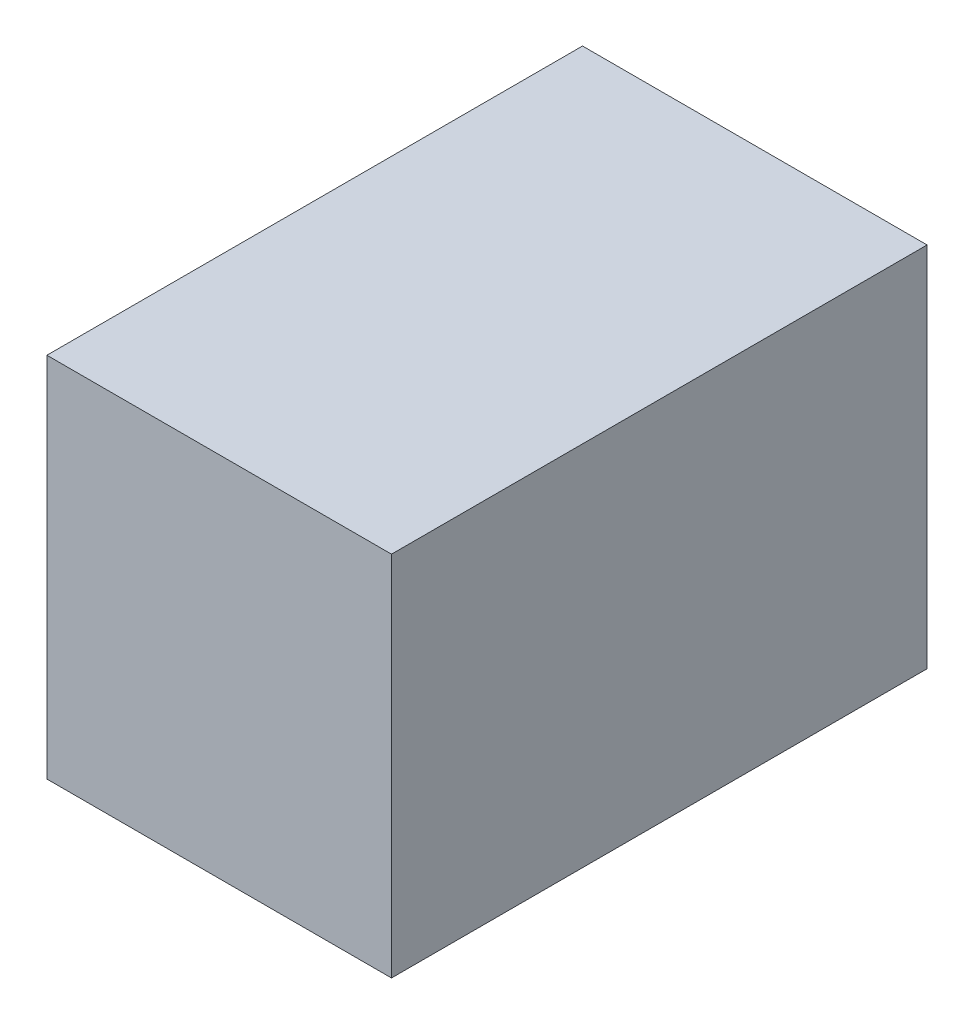
from build123d import *

# Parameters (mm, degrees)
SKETCH4_W           = 31.75
SKETCH4_H           = 20.5
BOSS_EXTRUDE1_DEPTH = 21
SHELL1_T            = 2
SKETCH5_W           = 12
SKETCH5_H           = 20.5
CUT_EXTRUDE1_DEPTH  = 2


with BuildPart() as part:
    # Sketch4 → Boss-Extrude1 (new body)
    with BuildSketch(Plane(origin=(0, 0, 0), x_dir=(0, 0, -1), z_dir=(1, 0, 0))):
        Rectangle(SKETCH4_W, SKETCH4_H)
    extrude(amount=BOSS_EXTRUDE1_DEPTH)

    # Shell1
    shell1_openings = [part.faces().sort_by_distance(p)[0] for p in [
        (0, 0, 0),
    ]]
    offset(amount=SHELL1_T, openings=shell1_openings, kind=Kind.INTERSECTION)

    # Sketch5 → Cut-Extrude1 (cut)
    with BuildSketch(Plane(origin=(0, 0, -17.875), x_dir=(-1, 0, 0), z_dir=(0, 0, -1))):
        with Locations((-6, 0)):
            Rectangle(SKETCH5_W, SKETCH5_H)
    extrude(amount=-CUT_EXTRUDE1_DEPTH, mode=Mode.SUBTRACT)


solid = part.part
